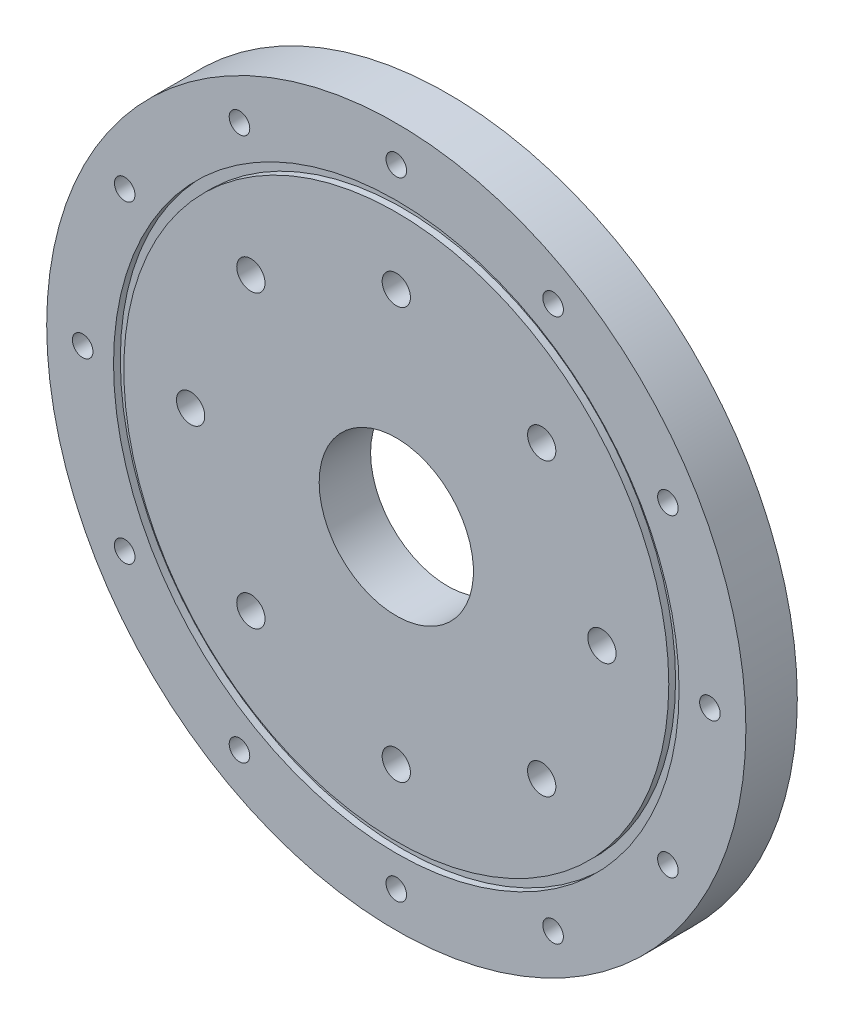
from build123d import *

# Parameters (mm, degrees)
SKETCH1_R                               = 75
BOSS_EXTRUDE1_DEPTH                     = 10
SKETCH3_R                               = 4.5
CUT_EXTRUDE2_DEPTH                      = 10
SKETCH5_W                               = 2.667
SKETCH5_H                               = 4.572
SKETCH6_R                               = 55
SKETCH6_R_2                             = 53
CUT_EXTRUDE3_DEPTH                      = 1.3208
SKETCH10_R                              = 2
CUT_EXTRUDE6_DEPTH                      = 11
CBORE_FOR_M5_HEX_HEAD_BOLT1_D           = 5.5
CBORE_FOR_M5_HEX_HEAD_BOLT1_CBORE_D     = 12.238
CBORE_FOR_M5_HEX_HEAD_BOLT1_CBORE_DEPTH = 3.5
SKETCH16_R                              = 75
SKETCH16_R_2                            = 68
CUT_EXTRUDE10_DEPTH                     = 10
CIRPATTERN1_COUNT                       = 12
CIRPATTERN2_COUNT                       = 8
SKETCH17_R                              = 6.119
CUT_EXTRUDE11_DEPTH                     = 5
CIRPATTERN3_COUNT                       = 8
SKETCH18_R                              = 15
CUT_EXTRUDE12_DEPTH                     = 10


with BuildPart() as part:
    # Sketch1 → Boss-Extrude1 (new body)
    with BuildSketch(Plane.XY):
        Circle(SKETCH1_R)
    extrude(amount=BOSS_EXTRUDE1_DEPTH)

    # Sketch3 → Cut-Extrude2 (cut)
    with BuildSketch(Plane.XY.offset(10)):
        Circle(SKETCH3_R)
    extrude(amount=-CUT_EXTRUDE2_DEPTH, mode=Mode.SUBTRACT)

    # Sketch5 → Cut-Revolve1 (revolve, cut)
    with BuildSketch(Plane(origin=(0, 0, 0), x_dir=(0, 0, -1), z_dir=(1, 0, 0))):
        with Locations((-1.3335, 24.8666)):
            Rectangle(SKETCH5_W, SKETCH5_H)
    revolve(axis=Axis((0, 0, 0), (0, 0, -1)), mode=Mode.SUBTRACT)

    # Sketch6 → Cut-Extrude3 (cut)
    with BuildSketch(Plane.XY.offset(10)):
        Circle(SKETCH6_R)
        Circle(SKETCH6_R_2, mode=Mode.SUBTRACT)
    extrude(amount=-CUT_EXTRUDE3_DEPTH, mode=Mode.SUBTRACT)

    # Sketch10 → Cut-Extrude6 (cut, through all)
    with BuildSketch(Plane(origin=(0, 0, 0), x_dir=(-1, 0, 0), z_dir=(0, 0, -1))):
        with Locations((0, 61)):
            Circle(SKETCH10_R)
    cut_extrude6 = extrude(amount=-CUT_EXTRUDE6_DEPTH, mode=Mode.SUBTRACT)

    # CBORE for M5 Hex Head Bolt1 (through all)
    with Locations(Plane(origin=(0, 0, 0), x_dir=(-1, 0, 0), z_dir=(0, 0, -1))):
        with Locations((-28.284271247, 28.284271247)):
            cbore_for_m5_hex_head_bolt1 = CounterBoreHole(CBORE_FOR_M5_HEX_HEAD_BOLT1_D / 2, CBORE_FOR_M5_HEX_HEAD_BOLT1_CBORE_D / 2, CBORE_FOR_M5_HEX_HEAD_BOLT1_CBORE_DEPTH)

    # Sketch16 → Cut-Extrude10 (cut)
    with BuildSketch(Plane(origin=(0, 0, 0), x_dir=(-1, 0, 0), z_dir=(0, 0, -1))):
        Circle(SKETCH16_R)
        Circle(SKETCH16_R_2, mode=Mode.SUBTRACT)
    extrude(amount=-CUT_EXTRUDE10_DEPTH, mode=Mode.SUBTRACT)

    # CirPattern1: Cut-Extrude6 ×12 about axis
    cirpattern1_axis = Axis((0, 0, 0), (0, 0, 1))
    for i in range(1, CIRPATTERN1_COUNT):
        add(cut_extrude6.rotate(cirpattern1_axis, i * 360 / CIRPATTERN1_COUNT), mode=Mode.SUBTRACT)

    # CirPattern2: CBORE for M5 Hex Head Bolt1 ×8 about axis
    cirpattern2_axis = Axis((0, 0, 0), (0, 0, 1))
    for i in range(1, CIRPATTERN2_COUNT):
        add(cbore_for_m5_hex_head_bolt1.rotate(cirpattern2_axis, i * 360 / CIRPATTERN2_COUNT), mode=Mode.SUBTRACT)

    # Sketch17 → Cut-Extrude11 (cut)
    with BuildSketch(Plane(origin=(0, 0, 0), x_dir=(-1, 0, 0), z_dir=(0, 0, -1))):
        with Locations((-28.284271247, 28.284271247)):
            Circle(SKETCH17_R)
    cut_extrude11 = extrude(amount=-CUT_EXTRUDE11_DEPTH, mode=Mode.SUBTRACT)

    # CirPattern3: Cut-Extrude11 ×8 about axis
    cirpattern3_axis = Axis((0, 0, 0), (0, 0, -1))
    for i in range(1, CIRPATTERN3_COUNT):
        add(cut_extrude11.rotate(cirpattern3_axis, i * 360 / CIRPATTERN3_COUNT), mode=Mode.SUBTRACT)

    # Sketch18 → Cut-Extrude12 (cut)
    with BuildSketch(Plane(origin=(0, 0, 0), x_dir=(-1, 0, 0), z_dir=(0, 0, -1))):
        Circle(SKETCH18_R)
    extrude(amount=-CUT_EXTRUDE12_DEPTH, mode=Mode.SUBTRACT)


solid = part.part
